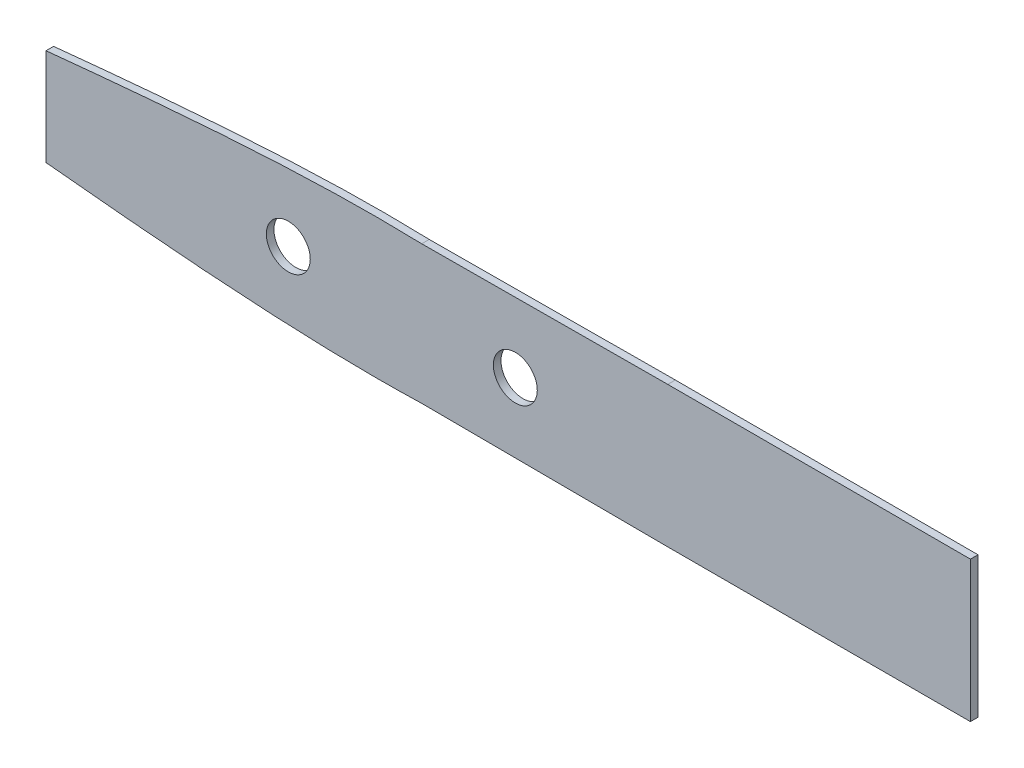
from build123d import *

# Parameters (mm, degrees)
SKETCH1_R           = 3.683
BOSS_EXTRUDE1_DEPTH = 1.27


with BuildPart() as part:
    # Sketch1 → Boss-Extrude1 (new body)
    with BuildSketch(Plane.XY):
        with BuildLine():
            Line((-67.928698338, 11.165767897), (-67.928698338, -5.09495887))
            add(Edge.make_bspline(
                [(-67.928698338, -5.09495887), (-65.317150891, -5.357271388), (-59.445047559, -5.93539969), (-50.370544126, -6.763807956), (-40.79988194, -7.532686473), (-31.506289085, -8.137699048), (-22.575311372, -8.541135315), (-14.081486566, -8.712534782), (-8.230455293, -8.660353622), (-5.219485256, -8.571038003), (-4.87655586, -8.560021553)],
                knots=[0.615514615, 0.615514615, 0.615514615, 0.615514615, 0.63604571, 0.661669949, 0.686792378, 0.711149584, 0.734517597, 0.75671861, 0.777596499, 0.780280213, 0.780280213, 0.780280213, 0.780280213], degree=3))
            Line((-4.87655586, -8.560021553), (36.414501662, -8.775595487))
            Line((36.414501662, -8.775595487), (87.214501662, -8.775595487))
            Line((87.214501662, -8.775595487), (87.214501662, 14.846404513))
            Line((87.214501662, 14.846404513), (36.414501662, 14.846404513))
            Line((36.414501662, 14.846404513), (-4.87655586, 14.63083058))
            add(Edge.make_bspline(
                [(-4.87655586, 14.63083058), (-5.219485256, 14.64184703), (-8.230455293, 14.731162649), (-14.081486566, 14.783343809), (-22.575311372, 14.611944341), (-31.506289085, 14.208508075), (-40.79988194, 13.6034955), (-50.370544126, 12.834616983), (-59.445047559, 12.006208717), (-65.317150891, 11.428080415), (-67.928698338, 11.165767897)],
                knots=[0.219719787, 0.219719787, 0.219719787, 0.219719787, 0.222403501, 0.24328139, 0.265482403, 0.288850416, 0.313207622, 0.338330051, 0.36395429, 0.384485385, 0.384485385, 0.384485385, 0.384485385], degree=3))
        make_face()
        with Locations((10.836701662, 3.035404513)):
            Circle(SKETCH1_R, mode=Mode.SUBTRACT)
        with Locations((-27.263298338, 3.035404513)):
            Circle(SKETCH1_R, mode=Mode.SUBTRACT)
    extrude(amount=BOSS_EXTRUDE1_DEPTH)


solid = part.part
